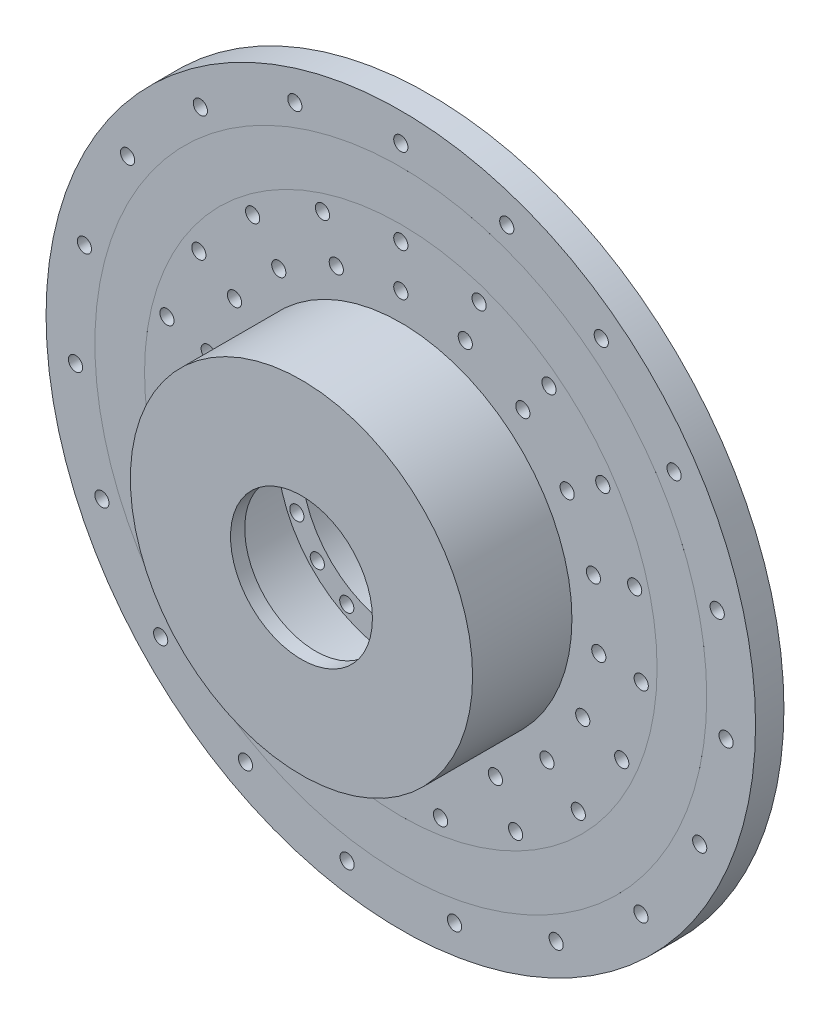
from build123d import *

# Parameters (mm, degrees)
SKETCH1_R                = 125
SKETCH1_R_2              = 35
SKETCH1_R_3              = 2.5
BOSS_EXTRUDE1_DEPTH      = 10
SKETCH2_R                = 60.29579013
SKETCH2_R_2              = 43.588302538
BOSS_EXTRUDE2_DEPTH      = 30
SKETCH3_R                = 60.29579013
BOSS_EXTRUDE3_DEPTH      = 5
SKETCH4_R                = 25
CUT_EXTRUDE2_DEPTH       = 47.5
SKETCH5_R                = 107.79610162
SKETCH5_R_2              = 90.298614491
BOSS_EXTRUDE4_DEPTH      = 10.001
BOSS_EXTRUDE4_DEPTH_BACK = 0.001


with BuildPart() as part:
    # Sketch1 → Boss-Extrude1 (new body)
    with BuildSketch(Plane.XY):
        Circle(SKETCH1_R)
        Circle(SKETCH1_R_2, mode=Mode.SUBTRACT)
        with Locations((0, 40)):
            Circle(SKETCH1_R_3, mode=Mode.SUBTRACT)
        with Locations((0, 55)):
            Circle(SKETCH1_R_3, mode=Mode.SUBTRACT)
        with Locations((0, 70)):
            Circle(SKETCH1_R_3, mode=Mode.SUBTRACT)
        with Locations((0, 85)):
            Circle(SKETCH1_R_3, mode=Mode.SUBTRACT)
        with Locations((0, 100)):
            Circle(SKETCH1_R_3, mode=Mode.SUBTRACT)
        with Locations((0, 115)):
            Circle(SKETCH1_R_3, mode=Mode.SUBTRACT)
        with Locations((37.340438959, 108.768982796)):
            Circle(SKETCH1_R_3, mode=Mode.SUBTRACT)
        with Locations((32.46994692, 94.58172417)):
            Circle(SKETCH1_R_3, mode=Mode.SUBTRACT)
        with Locations((27.599454882, 80.394465545)):
            Circle(SKETCH1_R_3, mode=Mode.SUBTRACT)
        with Locations((22.728962844, 66.207206919)):
            Circle(SKETCH1_R_3, mode=Mode.SUBTRACT)
        with Locations((17.858470806, 52.019948294)):
            Circle(SKETCH1_R_3, mode=Mode.SUBTRACT)
        with Locations((12.987978768, 37.832689668)):
            Circle(SKETCH1_R_3, mode=Mode.SUBTRACT)
        with Locations((70.634461959, 90.751158581)):
            Circle(SKETCH1_R_3, mode=Mode.SUBTRACT)
        with Locations((61.421271269, 78.91405094)):
            Circle(SKETCH1_R_3, mode=Mode.SUBTRACT)
        with Locations((52.208080579, 67.076943299)):
            Circle(SKETCH1_R_3, mode=Mode.SUBTRACT)
        with Locations((42.994889888, 55.239835658)):
            Circle(SKETCH1_R_3, mode=Mode.SUBTRACT)
        with Locations((33.781699198, 43.402728017)):
            Circle(SKETCH1_R_3, mode=Mode.SUBTRACT)
        with Locations((24.568508508, 31.565620376)):
            Circle(SKETCH1_R_3, mode=Mode.SUBTRACT)
        with Locations((96.274145, 62.899038184)):
            Circle(SKETCH1_R_3, mode=Mode.SUBTRACT)
        with Locations((83.716647826, 54.694815812)):
            Circle(SKETCH1_R_3, mode=Mode.SUBTRACT)
        with Locations((71.159150652, 46.49059344)):
            Circle(SKETCH1_R_3, mode=Mode.SUBTRACT)
        with Locations((58.601653478, 38.286371069)):
            Circle(SKETCH1_R_3, mode=Mode.SUBTRACT)
        with Locations((46.044156304, 30.082148697)):
            Circle(SKETCH1_R_3, mode=Mode.SUBTRACT)
        with Locations((33.486659131, 21.877926325)):
            Circle(SKETCH1_R_3, mode=Mode.SUBTRACT)
        with Locations((111.481030583, 28.230831021)):
            Circle(SKETCH1_R_3, mode=Mode.SUBTRACT)
        with Locations((96.940026594, 24.548548714)):
            Circle(SKETCH1_R_3, mode=Mode.SUBTRACT)
        with Locations((82.399022605, 20.866266407)):
            Circle(SKETCH1_R_3, mode=Mode.SUBTRACT)
        with Locations((67.858018616, 17.1839841)):
            Circle(SKETCH1_R_3, mode=Mode.SUBTRACT)
        with Locations((53.317014627, 13.501701793)):
            Circle(SKETCH1_R_3, mode=Mode.SUBTRACT)
        with Locations((38.776010638, 9.819419486)):
            Circle(SKETCH1_R_3, mode=Mode.SUBTRACT)
        with Locations((114.607216696, -9.496624729)):
            Circle(SKETCH1_R_3, mode=Mode.SUBTRACT)
        with Locations((99.658449301, -8.257934547)):
            Circle(SKETCH1_R_3, mode=Mode.SUBTRACT)
        with Locations((84.709681906, -7.019244365)):
            Circle(SKETCH1_R_3, mode=Mode.SUBTRACT)
        with Locations((69.76091451, -5.780554183)):
            Circle(SKETCH1_R_3, mode=Mode.SUBTRACT)
        with Locations((54.812147115, -4.541864001)):
            Circle(SKETCH1_R_3, mode=Mode.SUBTRACT)
        with Locations((39.86337972, -3.303173819)):
            Circle(SKETCH1_R_3, mode=Mode.SUBTRACT)
        with Locations((105.313932565, -46.194973835)):
            Circle(SKETCH1_R_3, mode=Mode.SUBTRACT)
        with Locations((91.577332666, -40.169542465)):
            Circle(SKETCH1_R_3, mode=Mode.SUBTRACT)
        with Locations((77.840732766, -34.144111095)):
            Circle(SKETCH1_R_3, mode=Mode.SUBTRACT)
        with Locations((64.104132866, -28.118679726)):
            Circle(SKETCH1_R_3, mode=Mode.SUBTRACT)
        with Locations((50.367532966, -22.093248356)):
            Circle(SKETCH1_R_3, mode=Mode.SUBTRACT)
        with Locations((36.630933066, -16.067816986)):
            Circle(SKETCH1_R_3, mode=Mode.SUBTRACT)
        with Locations((84.608249727, -77.887380737)):
            Circle(SKETCH1_R_3, mode=Mode.SUBTRACT)
        with Locations((73.572391067, -67.728157163)):
            Circle(SKETCH1_R_3, mode=Mode.SUBTRACT)
        with Locations((62.536532407, -57.568933588)):
            Circle(SKETCH1_R_3, mode=Mode.SUBTRACT)
        with Locations((51.500673747, -47.409710014)):
            Circle(SKETCH1_R_3, mode=Mode.SUBTRACT)
        with Locations((40.464815087, -37.250486439)):
            Circle(SKETCH1_R_3, mode=Mode.SUBTRACT)
        with Locations((29.428956427, -27.091262865)):
            Circle(SKETCH1_R_3, mode=Mode.SUBTRACT)
        with Locations((54.733950199, -101.139481389)):
            Circle(SKETCH1_R_3, mode=Mode.SUBTRACT)
        with Locations((47.594739304, -87.947375121)):
            Circle(SKETCH1_R_3, mode=Mode.SUBTRACT)
        with Locations((40.455528408, -74.755268853)):
            Circle(SKETCH1_R_3, mode=Mode.SUBTRACT)
        with Locations((33.316317513, -61.563162584)):
            Circle(SKETCH1_R_3, mode=Mode.SUBTRACT)
        with Locations((26.177106617, -48.371056316)):
            Circle(SKETCH1_R_3, mode=Mode.SUBTRACT)
        with Locations((19.037895722, -35.178950048)):
            Circle(SKETCH1_R_3, mode=Mode.SUBTRACT)
        with Locations((18.928377882, -113.431549891)):
            Circle(SKETCH1_R_3, mode=Mode.SUBTRACT)
        with Locations((16.459459028, -98.63613034)):
            Circle(SKETCH1_R_3, mode=Mode.SUBTRACT)
        with Locations((13.990540174, -83.840710789)):
            Circle(SKETCH1_R_3, mode=Mode.SUBTRACT)
        with Locations((11.52162132, -69.045291238)):
            Circle(SKETCH1_R_3, mode=Mode.SUBTRACT)
        with Locations((9.052702465, -54.249871687)):
            Circle(SKETCH1_R_3, mode=Mode.SUBTRACT)
        with Locations((6.583783611, -39.454452136)):
            Circle(SKETCH1_R_3, mode=Mode.SUBTRACT)
        with Locations((-18.928377882, -113.431549891)):
            Circle(SKETCH1_R_3, mode=Mode.SUBTRACT)
        with Locations((-16.459459028, -98.63613034)):
            Circle(SKETCH1_R_3, mode=Mode.SUBTRACT)
        with Locations((-13.990540174, -83.840710789)):
            Circle(SKETCH1_R_3, mode=Mode.SUBTRACT)
        with Locations((-11.52162132, -69.045291238)):
            Circle(SKETCH1_R_3, mode=Mode.SUBTRACT)
        with Locations((-9.052702465, -54.249871687)):
            Circle(SKETCH1_R_3, mode=Mode.SUBTRACT)
        with Locations((-6.583783611, -39.454452136)):
            Circle(SKETCH1_R_3, mode=Mode.SUBTRACT)
        with Locations((-54.733950199, -101.139481389)):
            Circle(SKETCH1_R_3, mode=Mode.SUBTRACT)
        with Locations((-47.594739304, -87.947375121)):
            Circle(SKETCH1_R_3, mode=Mode.SUBTRACT)
        with Locations((-40.455528408, -74.755268853)):
            Circle(SKETCH1_R_3, mode=Mode.SUBTRACT)
        with Locations((-33.316317513, -61.563162584)):
            Circle(SKETCH1_R_3, mode=Mode.SUBTRACT)
        with Locations((-26.177106617, -48.371056316)):
            Circle(SKETCH1_R_3, mode=Mode.SUBTRACT)
        with Locations((-19.037895721, -35.178950048)):
            Circle(SKETCH1_R_3, mode=Mode.SUBTRACT)
        with Locations((-84.608249727, -77.887380737)):
            Circle(SKETCH1_R_3, mode=Mode.SUBTRACT)
        with Locations((-73.572391067, -67.728157163)):
            Circle(SKETCH1_R_3, mode=Mode.SUBTRACT)
        with Locations((-62.536532407, -57.568933588)):
            Circle(SKETCH1_R_3, mode=Mode.SUBTRACT)
        with Locations((-51.500673747, -47.409710014)):
            Circle(SKETCH1_R_3, mode=Mode.SUBTRACT)
        with Locations((-40.464815087, -37.250486439)):
            Circle(SKETCH1_R_3, mode=Mode.SUBTRACT)
        with Locations((-29.428956427, -27.091262865)):
            Circle(SKETCH1_R_3, mode=Mode.SUBTRACT)
        with Locations((-105.313932565, -46.194973835)):
            Circle(SKETCH1_R_3, mode=Mode.SUBTRACT)
        with Locations((-91.577332665, -40.169542465)):
            Circle(SKETCH1_R_3, mode=Mode.SUBTRACT)
        with Locations((-77.840732766, -34.144111096)):
            Circle(SKETCH1_R_3, mode=Mode.SUBTRACT)
        with Locations((-64.104132866, -28.118679726)):
            Circle(SKETCH1_R_3, mode=Mode.SUBTRACT)
        with Locations((-50.367532966, -22.093248356)):
            Circle(SKETCH1_R_3, mode=Mode.SUBTRACT)
        with Locations((-36.630933066, -16.067816986)):
            Circle(SKETCH1_R_3, mode=Mode.SUBTRACT)
        with Locations((-114.607216696, -9.496624729)):
            Circle(SKETCH1_R_3, mode=Mode.SUBTRACT)
        with Locations((-99.658449301, -8.257934547)):
            Circle(SKETCH1_R_3, mode=Mode.SUBTRACT)
        with Locations((-84.709681906, -7.019244365)):
            Circle(SKETCH1_R_3, mode=Mode.SUBTRACT)
        with Locations((-69.76091451, -5.780554183)):
            Circle(SKETCH1_R_3, mode=Mode.SUBTRACT)
        with Locations((-54.812147115, -4.541864001)):
            Circle(SKETCH1_R_3, mode=Mode.SUBTRACT)
        with Locations((-39.86337972, -3.303173819)):
            Circle(SKETCH1_R_3, mode=Mode.SUBTRACT)
        with Locations((-111.481030583, 28.230831021)):
            Circle(SKETCH1_R_3, mode=Mode.SUBTRACT)
        with Locations((-96.940026594, 24.548548714)):
            Circle(SKETCH1_R_3, mode=Mode.SUBTRACT)
        with Locations((-82.399022605, 20.866266407)):
            Circle(SKETCH1_R_3, mode=Mode.SUBTRACT)
        with Locations((-67.858018616, 17.1839841)):
            Circle(SKETCH1_R_3, mode=Mode.SUBTRACT)
        with Locations((-53.317014627, 13.501701793)):
            Circle(SKETCH1_R_3, mode=Mode.SUBTRACT)
        with Locations((-38.776010638, 9.819419486)):
            Circle(SKETCH1_R_3, mode=Mode.SUBTRACT)
        with Locations((-96.274145, 62.899038184)):
            Circle(SKETCH1_R_3, mode=Mode.SUBTRACT)
        with Locations((-83.716647826, 54.694815812)):
            Circle(SKETCH1_R_3, mode=Mode.SUBTRACT)
        with Locations((-71.159150652, 46.49059344)):
            Circle(SKETCH1_R_3, mode=Mode.SUBTRACT)
        with Locations((-58.601653478, 38.286371069)):
            Circle(SKETCH1_R_3, mode=Mode.SUBTRACT)
        with Locations((-46.044156304, 30.082148697)):
            Circle(SKETCH1_R_3, mode=Mode.SUBTRACT)
        with Locations((-33.48665913, 21.877926325)):
            Circle(SKETCH1_R_3, mode=Mode.SUBTRACT)
        with Locations((-70.634461959, 90.751158581)):
            Circle(SKETCH1_R_3, mode=Mode.SUBTRACT)
        with Locations((-61.421271269, 78.91405094)):
            Circle(SKETCH1_R_3, mode=Mode.SUBTRACT)
        with Locations((-52.208080579, 67.076943299)):
            Circle(SKETCH1_R_3, mode=Mode.SUBTRACT)
        with Locations((-42.994889888, 55.239835658)):
            Circle(SKETCH1_R_3, mode=Mode.SUBTRACT)
        with Locations((-33.781699198, 43.402728017)):
            Circle(SKETCH1_R_3, mode=Mode.SUBTRACT)
        with Locations((-24.568508508, 31.565620376)):
            Circle(SKETCH1_R_3, mode=Mode.SUBTRACT)
        with Locations((-37.340438959, 108.768982796)):
            Circle(SKETCH1_R_3, mode=Mode.SUBTRACT)
        with Locations((-32.46994692, 94.58172417)):
            Circle(SKETCH1_R_3, mode=Mode.SUBTRACT)
        with Locations((-27.599454882, 80.394465545)):
            Circle(SKETCH1_R_3, mode=Mode.SUBTRACT)
        with Locations((-22.728962844, 66.207206919)):
            Circle(SKETCH1_R_3, mode=Mode.SUBTRACT)
        with Locations((-17.858470806, 52.019948294)):
            Circle(SKETCH1_R_3, mode=Mode.SUBTRACT)
        with Locations((-12.987978768, 37.832689668)):
            Circle(SKETCH1_R_3, mode=Mode.SUBTRACT)
    extrude(amount=BOSS_EXTRUDE1_DEPTH)

    # Sketch2 → Boss-Extrude2 (add)
    with BuildSketch(Plane.XY.offset(10)):
        Circle(SKETCH2_R)
        Circle(SKETCH2_R_2, mode=Mode.SUBTRACT)
    extrude(amount=BOSS_EXTRUDE2_DEPTH)

    # Sketch3 → Boss-Extrude3 (add)
    with BuildSketch(Plane.XY.offset(40)):
        Circle(SKETCH3_R)
    extrude(amount=BOSS_EXTRUDE3_DEPTH)

    # Sketch4 → Cut-Extrude2 (cut, symmetric)
    with BuildSketch(Plane(origin=(0, 0, 40), x_dir=(-1, 0, 0), z_dir=(0, 0, -1))):
        Circle(SKETCH4_R)
    extrude(amount=CUT_EXTRUDE2_DEPTH, both=True, mode=Mode.SUBTRACT)

    # Sketch5 → Boss-Extrude4 (add, two sides)
    with BuildSketch(Plane.XY) as boss_extrude4_sk:
        Circle(SKETCH5_R)
        Circle(SKETCH5_R_2, mode=Mode.SUBTRACT)
    extrude(amount=BOSS_EXTRUDE4_DEPTH)
    extrude(boss_extrude4_sk.sketch, amount=-BOSS_EXTRUDE4_DEPTH_BACK)


solid = part.part
